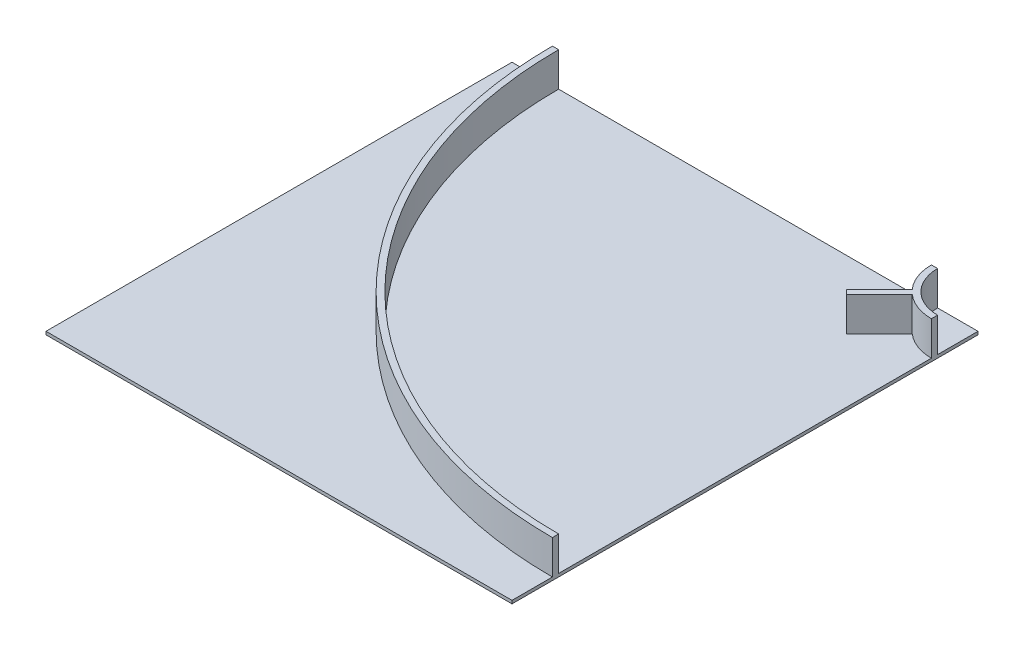
from build123d import *

# Parameters (mm, degrees)
SKETCH2_W           = 1500
SKETCH2_H           = 1500
BOSS_EXTRUDE1_DEPTH = 10
BOSS_EXTRUDE2_DEPTH = 110
BOSS_EXTRUDE3_DEPTH = 110


with BuildPart() as part:
    # Sketch2 → Boss-Extrude1 (new body)
    with BuildSketch(Plane(origin=(0, 0, 0), x_dir=(1, 0, 0), z_dir=(0, 1, 0))):
        Rectangle(SKETCH2_W, SKETCH2_H)
    extrude(amount=BOSS_EXTRUDE1_DEPTH)

    # Sketch3 → Boss-Extrude2 (add)
    with BuildSketch(Plane(origin=(0, 10, 0), x_dir=(1, 0, 0), z_dir=(0, 1, 0))):
        with BuildLine():
            ThreePointArc((750, -600), (-204.594154602, -204.594154602), (-600, 750))
            Line((-600, 750), (-620, 750))
            ThreePointArc((-620, 750), (-218.736290226, -218.736290226), (750, -620))
            Line((750, -620), (750, -600))
        make_face()
        with BuildLine():
            Line((620, 750), (600, 750))
            ThreePointArc((600, 750), (643.933982822, 643.933982822), (750, 600))
            Line((750, 600), (750, 620))
            ThreePointArc((750, 620), (658.076118446, 658.076118446), (620, 750))
        make_face()
    extrude(amount=BOSS_EXTRUDE2_DEPTH)

    # Sketch4 → Boss-Extrude3 (add)
    with BuildSketch(Plane(origin=(0, 10, 0), x_dir=(1, 0, 0), z_dir=(0, 1, 0))):
        Polygon((545.174998191, 531.032862568), (651.241015369, 637.098879746), (637.098879746, 651.241015369), (531.032862568, 545.174998191), align=None)
    extrude(amount=BOSS_EXTRUDE3_DEPTH)


solid = part.part
